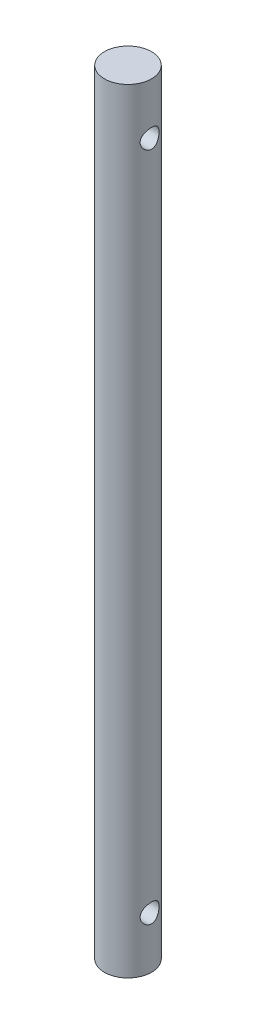
from build123d import *

# Parameters (mm, degrees)
SKETCH1_R           = 3.9624
BOSS_EXTRUDE1_DEPTH = 65.0875
SKETCH2_W           = 32.020580586
SKETCH2_H           = 1.5875


with BuildPart() as part:
    # Sketch1 → Boss-Extrude1 (new body, symmetric)
    with BuildSketch(Plane(origin=(0, 0, 0), x_dir=(1, 0, 0), z_dir=(0, 1, 0))):
        Circle(SKETCH1_R)
    extrude(amount=BOSS_EXTRUDE1_DEPTH, both=True)

    # Sketch2 → Cut-Revolve1 (revolve, cut)
    with BuildSketch(Plane.XY):
        with Locations((-1.023553281, 57.21985)):
            Rectangle(SKETCH2_W, SKETCH2_H)
    cut_revolve1 = revolve(axis=Axis((14.986737012, 56.4261, 0), (-1, 0, 0)), mode=Mode.SUBTRACT)

    # Mirror1: Cut-Revolve1 across plane
    add(cut_revolve1.mirror(Plane.ZX), mode=Mode.SUBTRACT)


solid = part.part
